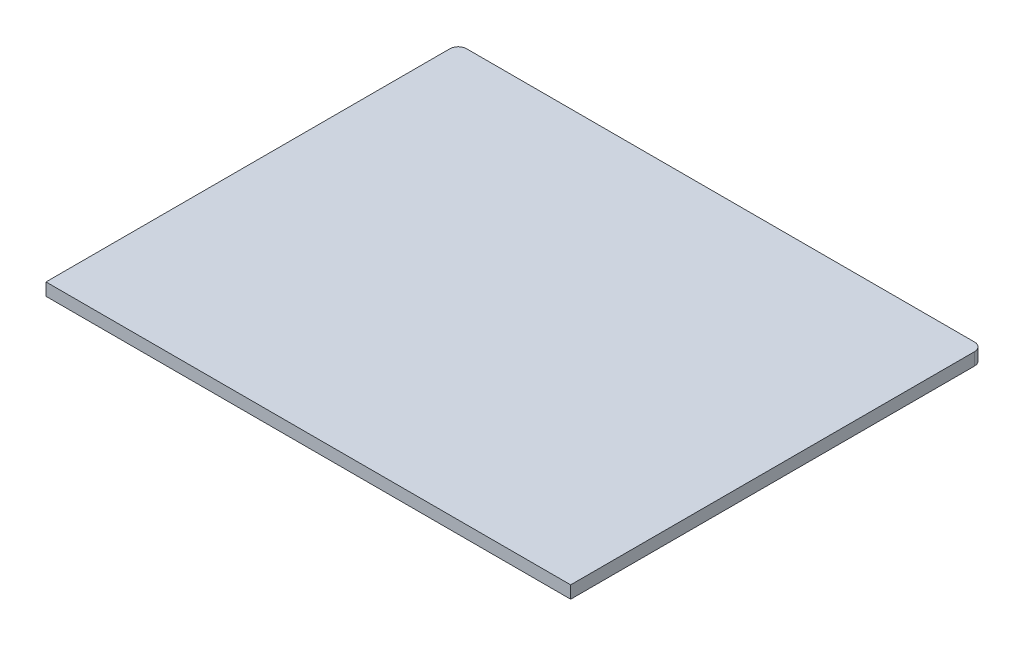
from build123d import *

# Parameters (mm, degrees)
SKETCH1_W           = 63
SKETCH1_H           = 57
BOSS_EXTRUDE1_DEPTH = 1.5
FILLET1_R           = 1
FILLET2_R           = 1
FILLET3_R           = 1
SKETCH3_W           = 63.057677914
SKETCH3_H           = 7.5
CUT_EXTRUDE2_DEPTH  = 10


with BuildPart() as part:
    # Sketch1 → Boss-Extrude1 (new body)
    with BuildSketch(Plane(origin=(0, 0, 0), x_dir=(1, 0, 0), z_dir=(0, 1, 0))):
        with Locations((23.995049505, -10.534653465)):
            Rectangle(SKETCH1_W, SKETCH1_H)
    extrude(amount=BOSS_EXTRUDE1_DEPTH)

    # Fillet1
    fillet1_edges = [part.edges().sort_by_distance(p)[0] for p in [
        (55.495049505, 0.75, 39.034653465),
    ]]
    fillet(fillet1_edges, radius=FILLET1_R)

    # Fillet2
    fillet2_edges = [part.edges().sort_by_distance(p)[0] for p in [
        (55.495049505, 0.75, -17.965346535),
    ]]
    fillet(fillet2_edges, radius=FILLET2_R)

    # Fillet3
    fillet3_edges = [part.edges().sort_by_distance(p)[0] for p in [
        (-7.504950495, 0.75, -17.965346535),
        (-7.504950495, 0.75, 39.034653465),
    ]]
    fillet(fillet3_edges, radius=FILLET3_R)

    # Sketch3 → Cut-Extrude2 (cut)
    with BuildSketch(Plane(origin=(0, 1.5, 0), x_dir=(1, 0, 0), z_dir=(0, 1, 0))):
        with Locations((24.023888462, -35.284653465)):
            Rectangle(SKETCH3_W, SKETCH3_H)
    extrude(amount=-CUT_EXTRUDE2_DEPTH, mode=Mode.SUBTRACT)


solid = part.part
